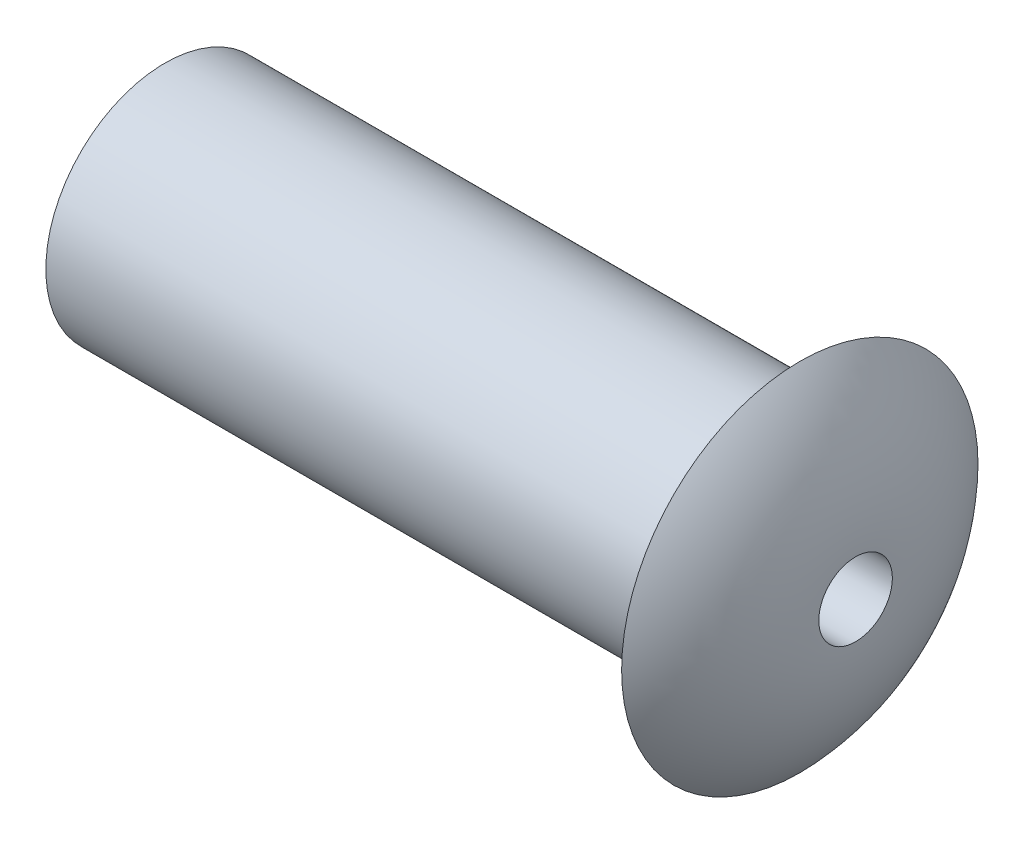
from build123d import *

# Parameters (mm, degrees)
SKETCH1_R           = 1.875
BOSS_EXTRUDE1_DEPTH = 10
SKETCH3_R           = 0.579460837
CUT_EXTRUDE1_DEPTH  = 1


with BuildPart() as part:
    # Sketch1 → Boss-Extrude1 (new body)
    with BuildSketch(Plane(origin=(82.969208633, 0, 0), x_dir=(0, 0, -1), z_dir=(1, 0, 0))):
        with Locations((-223, 21.8)):
            Circle(SKETCH1_R)
    extrude(amount=-BOSS_EXTRUDE1_DEPTH)

    # Sketch2 → Revolve1 (revolve)
    with BuildSketch(Plane.XY.offset(223)):
        with BuildLine():
            Line((83.847534734, 21.8), (82.969208633, 21.8))
            Line((82.969208633, 21.8), (82.969208633, 19.925))
            Line((82.969208633, 19.925), (82.969208633, 18.993573117))
            ThreePointArc((82.969208633, 18.993573117), (83.620019841, 20.02358109), (83.847534734, 21.220539163))
            Line((83.847534734, 21.220539163), (83.847534734, 21.8))
        make_face()
    revolve(axis=Axis((82.969208633, 21.8, 223), (1, 0, 0)))

    # Sketch3 → Cut-Extrude1 (cut)
    with BuildSketch(Plane(origin=(83.847534734, 0, 0), x_dir=(0, 0, -1), z_dir=(1, 0, 0))):
        with Locations((-223, 21.8)):
            Circle(SKETCH3_R)
    extrude(amount=-CUT_EXTRUDE1_DEPTH, mode=Mode.SUBTRACT)


solid = part.part
